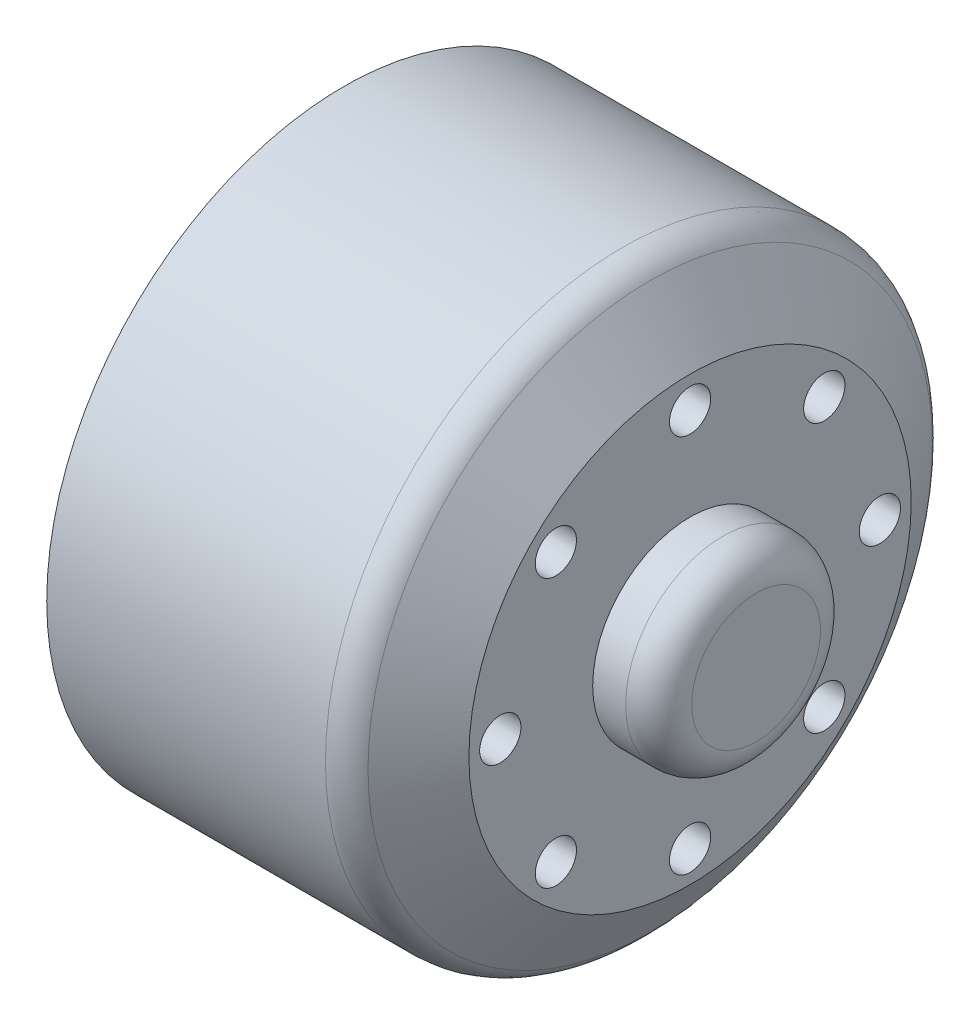
from build123d import *

# Parameters (mm, degrees)
SKETCH2_R          = 1.25
CUT_EXTRUDE1_DEPTH = 21.98
SKETCH3_R          = 2.5
CUT_EXTRUDE2_DEPTH = 15.98
SKETCH4_R          = 9.5
CUT_EXTRUDE3_DEPTH = 10
FILLET1_R          = 2
FILLET2_R          = 2


with BuildPart() as part:
    # Sketch1 → Revolve1 (revolve)
    with BuildSketch(Plane(origin=(0, 0, 0), x_dir=(1, 0, 0), z_dir=(0, 1, 0))):
        Polygon((7.143835403, 5.9), (7.143835403, 13.4), (4.13367975, 18), (-13.836164597, 18), (-13.836164597, 0), (7.143835403, 0), (11.143835403, 0), (11.143835403, 5.9), align=None)
    revolve(axis=Axis((-26.115988439, 0, 0), (1, 0, 0)))

    # Sketch2 → Cut-Extrude1 (cut, through all)
    with BuildSketch(Plane(origin=(7.143835403, 0, 0), x_dir=(0, 0, -1), z_dir=(1, 0, 0))):
        with Locations((0, 11.5)):
            Circle(SKETCH2_R)
        with Locations((8.131727984, 8.131727984)):
            Circle(SKETCH2_R)
        with Locations((11.5, 0)):
            Circle(SKETCH2_R)
        with Locations((8.131727984, -8.131727984)):
            Circle(SKETCH2_R)
        with Locations((0, -11.5)):
            Circle(SKETCH2_R)
        with Locations((-8.131727984, -8.131727984)):
            Circle(SKETCH2_R)
        with Locations((-11.5, 0)):
            Circle(SKETCH2_R)
        with Locations((-8.131727984, 8.131727984)):
            Circle(SKETCH2_R)
    extrude(amount=-CUT_EXTRUDE1_DEPTH, mode=Mode.SUBTRACT)

    # Sketch3 → Cut-Extrude2 (cut)
    with BuildSketch(Plane.ZY.offset(13.836164597)):
        with Locations((0, 11.5)):
            Circle(SKETCH3_R)
        with Locations((8.131727984, 8.131727984)):
            Circle(SKETCH3_R)
        with Locations((11.5, 0)):
            Circle(SKETCH3_R)
        with Locations((8.131727984, -8.131727984)):
            Circle(SKETCH3_R)
        with Locations((0, -11.5)):
            Circle(SKETCH3_R)
        with Locations((-8.131727984, -8.131727984)):
            Circle(SKETCH3_R)
        with Locations((-11.5, 0)):
            Circle(SKETCH3_R)
        with Locations((-8.131727984, 8.131727984)):
            Circle(SKETCH3_R)
    extrude(amount=-CUT_EXTRUDE2_DEPTH, mode=Mode.SUBTRACT)

    # Sketch4 → Cut-Extrude3 (cut)
    with BuildSketch(Plane.ZY.offset(13.836164597)):
        Circle(SKETCH4_R)
    extrude(amount=-CUT_EXTRUDE3_DEPTH, mode=Mode.SUBTRACT)

    # Fillet1
    fillet1_edges = [part.edges().sort_by_distance(p)[0] for p in [
        (11.143835403, 0, 5.9),
    ]]
    fillet(fillet1_edges, radius=FILLET1_R)

    # Fillet2
    fillet2_edges = [part.edges().sort_by_distance(p)[0] for p in [
        (4.13367975, 0, 18),
    ]]
    fillet(fillet2_edges, radius=FILLET2_R)


solid = part.part
